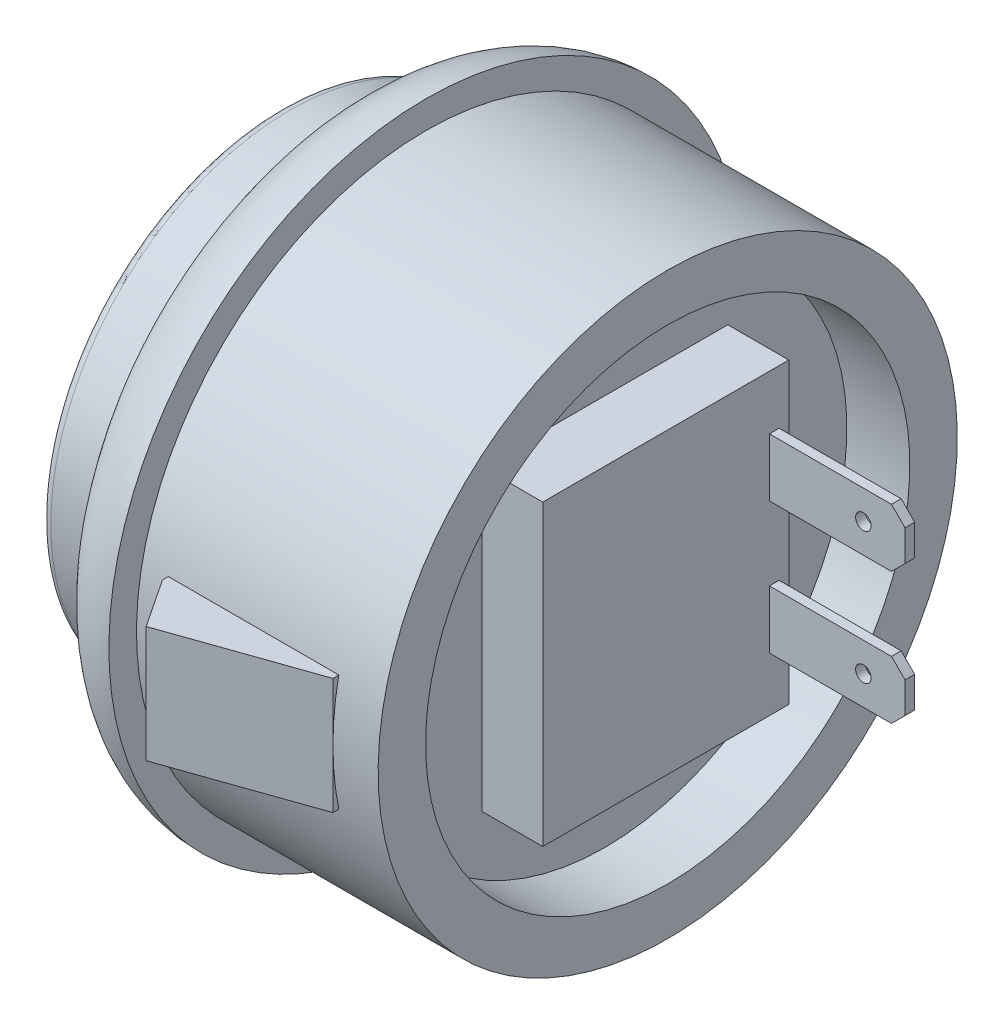
from build123d import *

# Parameters (mm, degrees)
SKETCH2_W           = 12.7
SKETCH2_H           = 15.4
BOSS_EXTRUDE1_DEPTH = 3.15
SKETCH3_W           = 0.5
SKETCH3_H           = 3
BOSS_EXTRUDE2_DEPTH = 7
SKETCH4_R           = 0.4
CUT_EXTRUDE1_DEPTH  = 23.225
CHAMFER1_SIZE       = 0.7
BOSS_EXTRUDE3_DEPTH = 3
FILLET1_R           = 0.5


with BuildPart() as part:
    # Sketch1 → Revolve1 (revolve)
    with BuildSketch(Plane.XY):
        with BuildLine():
            Line((0, 0), (0, 12.35))
            Line((0, 12.35), (3.5, 12.35))
            ThreePointArc((3.5, 12.35), (4.678895206, 15.196104794), (7.525, 16.375))
            Line((7.525, 16.375), (7.525, 14.95))
            Line((7.525, 14.95), (20, 14.95))
            Line((20, 14.95), (20, 12.5))
            Line((20, 12.5), (16.75, 12.5))
            Line((16.75, 12.5), (16.75, 0))
            Line((16.75, 0), (0, 0))
        make_face()
    revolve(axis=Axis((16.75, 0, 0), (-1, 0, 0)))

    # Sketch2 → Boss-Extrude1 (add)
    with BuildSketch(Plane(origin=(16.75, 0, 0), x_dir=(0, 0, -1), z_dir=(1, 0, 0))):
        Rectangle(SKETCH2_W, SKETCH2_H)
    extrude(amount=BOSS_EXTRUDE1_DEPTH)

    # Sketch3 → Boss-Extrude2 (add)
    with BuildSketch(Plane(origin=(19.9, 0, 0), x_dir=(0, 0, -1), z_dir=(1, 0, 0))):
        with Locations((5.6, 3.4)):
            Rectangle(SKETCH3_W, SKETCH3_H)
        with Locations((5.6, -3.4)):
            Rectangle(SKETCH3_W, SKETCH3_H)
    extrude(amount=BOSS_EXTRUDE2_DEPTH)

    # Sketch4 → Cut-Extrude1 (cut, through all)
    with BuildSketch(Plane(origin=(0, 0, -5.85), x_dir=(-1, 0, 0), z_dir=(0, 0, -1))):
        with Locations((-24.75, 3.4)):
            Circle(SKETCH4_R)
        with Locations((-24.75, -3.4)):
            Circle(SKETCH4_R)
    extrude(amount=-CUT_EXTRUDE1_DEPTH, mode=Mode.SUBTRACT)

    # Chamfer1
    chamfer1_edges = [part.edges().sort_by_distance(p)[0] for p in [
        (26.9, 1.9, -5.6),
        (26.9, 4.9, -5.6),
        (26.9, -4.9, -5.6),
        (26.9, -1.9, -5.6),
    ]]
    chamfer(chamfer1_edges, length=CHAMFER1_SIZE)

    # Sketch5 → Boss-Extrude3 (add, symmetric)
    with BuildSketch(Plane(origin=(0, 0, 0), x_dir=(1, 0, 0), z_dir=(0, 1, 0))):
        Polygon((17.666687605, -14.95), (10.525, -17.45), (8.866687605, -14.95), (8.866687605, -13.95), (17.666687605, -13.95), align=None)
        Polygon((8.866687605, 13.95), (8.866687605, 14.95), (10.525, 17.45), (17.666687605, 14.95), (17.666687605, 13.95), align=None)
    extrude(amount=BOSS_EXTRUDE3_DEPTH, both=True)

    # Fillet1
    fillet1_edges = [part.edges().sort_by_distance(p)[0] for p in [
        (0, -12.35, 0),
    ]]
    fillet(fillet1_edges, radius=FILLET1_R)


solid = part.part
